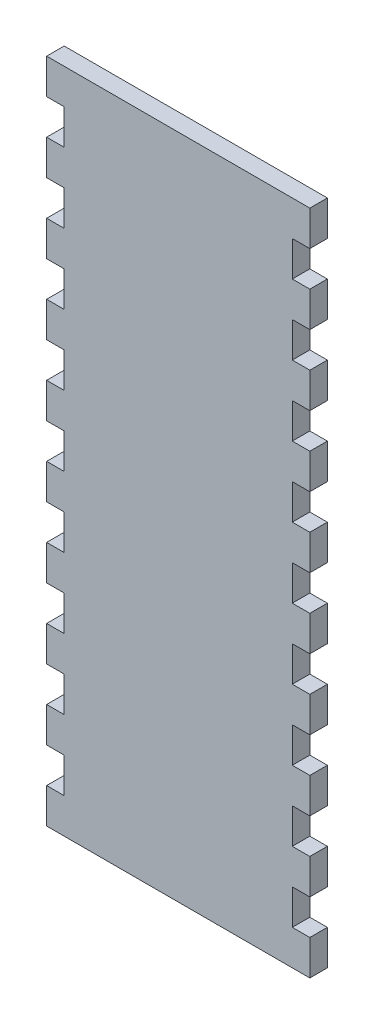
from build123d import *

# Parameters (mm, degrees)
SKETCH1_W           = 95.25
SKETCH1_H           = 241.3
BOSS_EXTRUDE1_DEPTH = 6.35
SKETCH2_W           = 6.35
SKETCH2_H           = 12.7
CUT_EXTRUDE1_DEPTH  = 7.35
LPATTERN1_COUNT     = 9
LPATTERN1_PITCH     = 25.4


with BuildPart() as part:
    # Sketch1 → Boss-Extrude1 (new body)
    with BuildSketch(Plane.XY):
        with Locations((47.625, 120.65)):
            Rectangle(SKETCH1_W, SKETCH1_H)
    extrude(amount=BOSS_EXTRUDE1_DEPTH)

    # Sketch2 → Cut-Extrude1 (cut, through all)
    with BuildSketch(Plane.XY.offset(6.35)):
        with Locations((3.175, 222.25)):
            Rectangle(SKETCH2_W, SKETCH2_H)
        with Locations((92.075, 222.25)):
            Rectangle(SKETCH2_W, SKETCH2_H)
    cut_extrude1 = extrude(amount=-CUT_EXTRUDE1_DEPTH, mode=Mode.SUBTRACT)

    # LPattern1: Cut-Extrude1 ×9
    with Locations(*[(0, -i * LPATTERN1_PITCH, 0) for i in range(1, LPATTERN1_COUNT)]):
        add(cut_extrude1, mode=Mode.SUBTRACT)


solid = part.part
